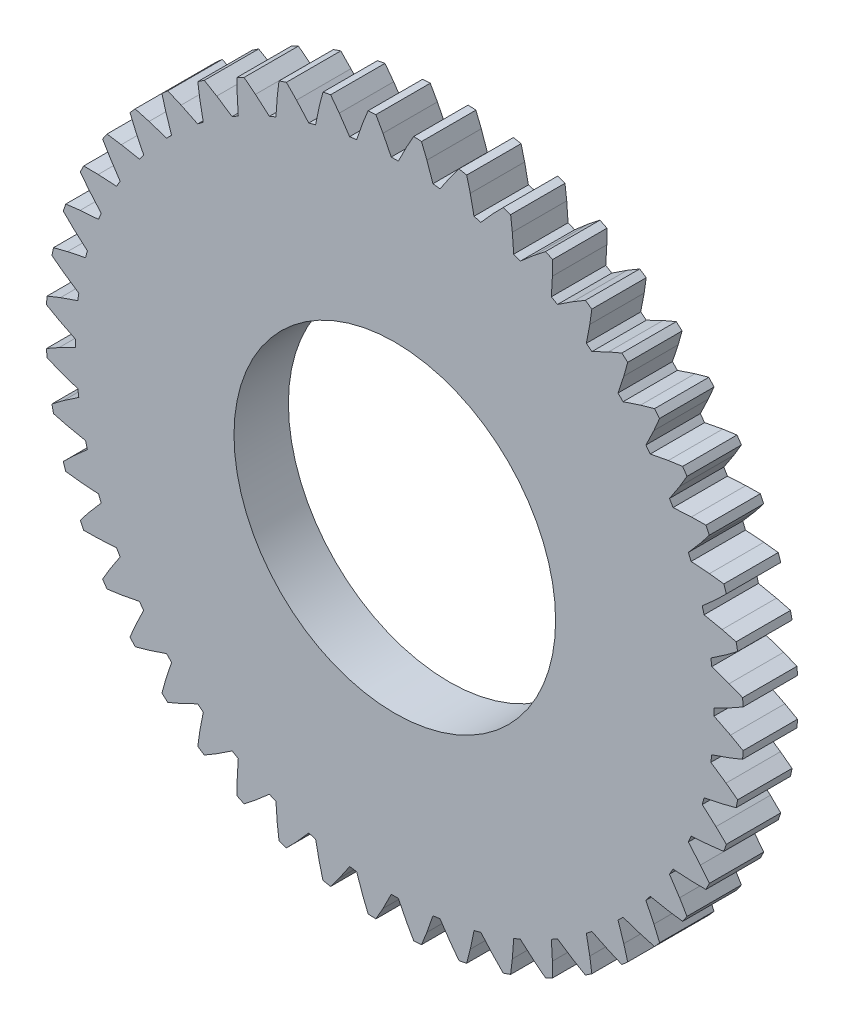
from build123d import *

# Parameters (mm, degrees)
CROQUIS1_R              = 7.375
SALIENTE_EXTRUIR1_DEPTH = 1.15
CORTAR_EXTRUIR1_DEPTH   = 1.3
MATRIZC1_COUNT          = 48
CROQUIS2_3_R            = 3.4
CORTAR_EXTRUIR2_DEPTH   = 2.1


with BuildPart() as part:
    # Croquis1 → Saliente-Extruir1 (new body)
    with BuildSketch(Plane.XY):
        Circle(CROQUIS1_R)
    extrude(amount=SALIENTE_EXTRUIR1_DEPTH)

    # Croquis2 → Cortar-Extruir1 (cut)
    with BuildSketch(Plane.XY.offset(1.15)):
        with BuildLine():
            ThreePointArc((-0.075, 6.74958332), (0, 6.75), (0.075, 6.74958332))
            Line((0.075, 6.74958332), (0.25, 7.097377716))
            Line((0.25, 7.097377716), (0.476389994, 7.5))
            Line((0.476389994, 7.5), (-0.476389994, 7.5))
            Line((-0.476389994, 7.5), (-0.25, 7.097377716))
            Line((-0.25, 7.097377716), (-0.075, 6.74958332))
        make_face()
    cortar_extruir1 = extrude(amount=-CORTAR_EXTRUIR1_DEPTH, mode=Mode.SUBTRACT)

    # MatrizC1: Cortar-Extruir1 ×48 about axis
    matrizc1_axis = Axis((0, 0, 1.15), (0, 0, -1))
    for i in range(1, MATRIZC1_COUNT):
        add(cortar_extruir1.rotate(matrizc1_axis, i * 360 / MATRIZC1_COUNT), mode=Mode.SUBTRACT)

    # Croquis2_3 → Cortar-Extruir2 (cut)
    with BuildSketch(Plane.XY.offset(1.15)):
        Circle(CROQUIS2_3_R)
    extrude(amount=-CORTAR_EXTRUIR2_DEPTH, mode=Mode.SUBTRACT)


solid = part.part
